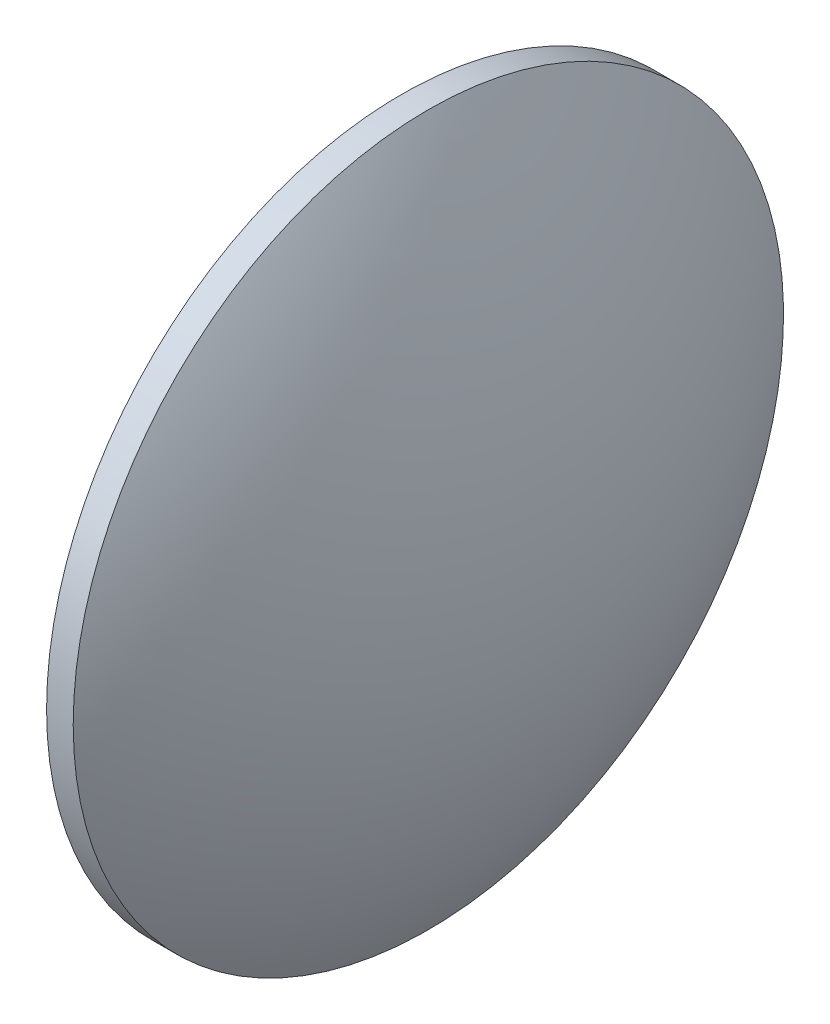
from build123d import *


with BuildPart() as part:
    # 草图1 → 旋转1 (revolve)
    with BuildSketch(Plane.XY):
        with BuildLine():
            Line((236.156126338, 130.04189076), (236.156126338, 170.04189076))
            Line((236.156126338, 170.04189076), (239.156126338, 170.04189076))
            ThreePointArc((239.156126338, 170.04189076), (247.444394385, 150.800349277), (250.276126338, 130.04189076))
            Line((250.276126338, 130.04189076), (236.156126338, 130.04189076))
        make_face()
    revolve(axis=Axis((217.331148661, 130.04189076, 0), (1, 0, 0)))


solid = part.part
